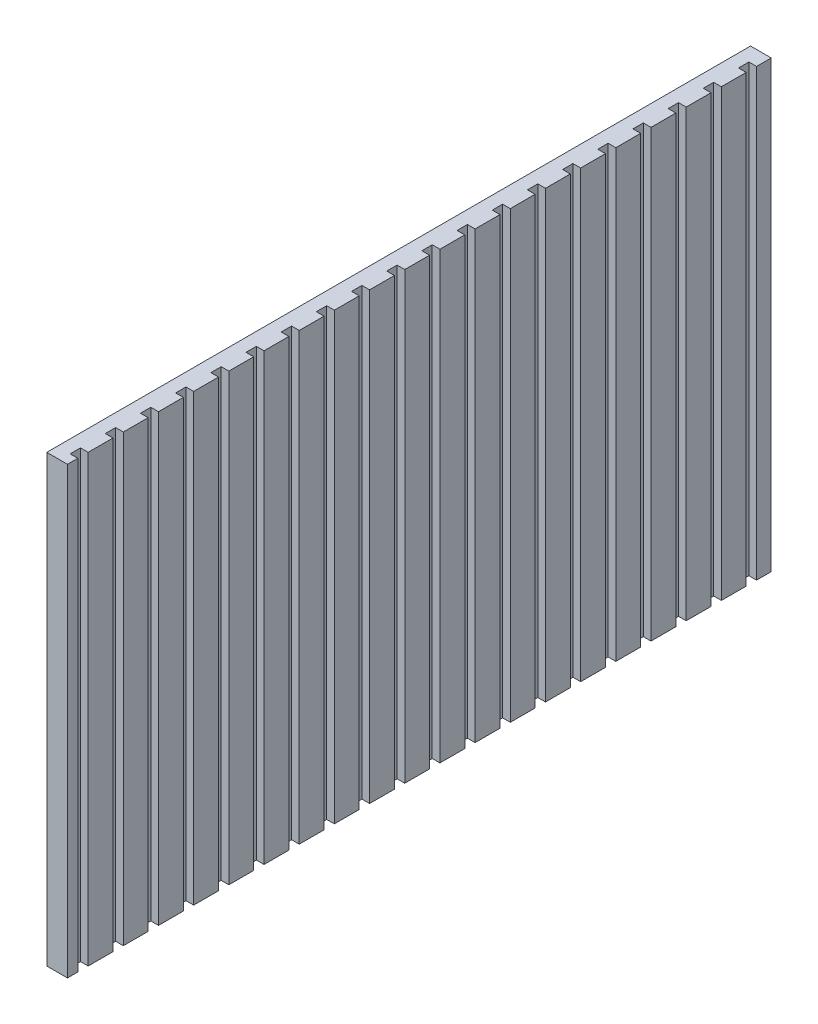
from build123d import *

# Parameters (mm, degrees)
SKETCH1_W           = 340.1
SKETCH1_H           = 215
BOSS_EXTRUDE1_DEPTH = 10
SKETCH2_W           = 7.43612634
SKETCH2_H           = 5
CUT_EXTRUDE1_DEPTH  = 216
LPATTERN1_COUNT     = 20
LPATTERN1_PITCH     = 17


with BuildPart() as part:
    # Sketch1 → Boss-Extrude1 (new body)
    with BuildSketch(Plane(origin=(0, 0, 0), x_dir=(0, 0, -1), z_dir=(1, 0, 0))):
        Rectangle(SKETCH1_W, SKETCH1_H)
    extrude(amount=BOSS_EXTRUDE1_DEPTH)

    # Sketch2 → Cut-Extrude1 (cut, through all)
    with BuildSketch(Plane(origin=(0, 107.5, 0), x_dir=(1, 0, 0), z_dir=(0, 1, 0))):
        with Locations((10, -162.55)):
            Rectangle(SKETCH2_W, SKETCH2_H)
    cut_extrude1 = extrude(amount=-CUT_EXTRUDE1_DEPTH, mode=Mode.SUBTRACT)

    # LPattern1: Cut-Extrude1 ×20
    with Locations(*[(0, 0, -i * LPATTERN1_PITCH) for i in range(1, LPATTERN1_COUNT)]):
        add(cut_extrude1, mode=Mode.SUBTRACT)


solid = part.part
